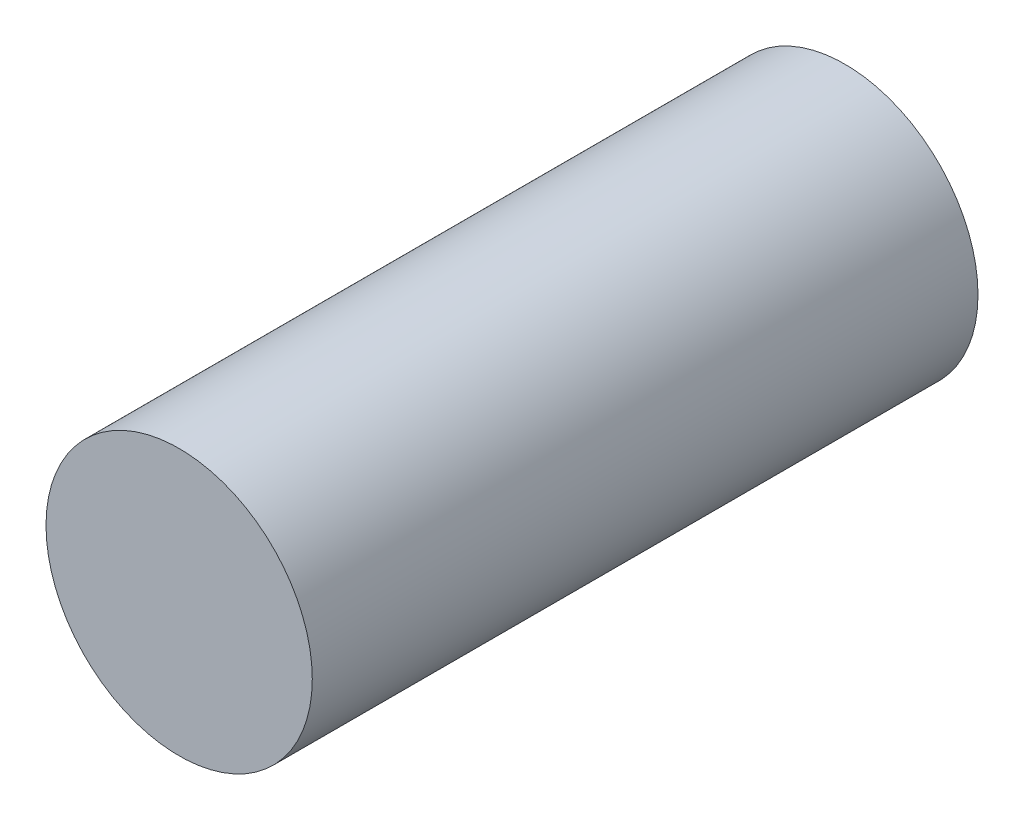
from build123d import *

# Parameters (mm, degrees)
SKETCH1_R           = 2
BOSS_EXTRUDE1_DEPTH = 10


with BuildPart() as part:
    # Sketch1 → Boss-Extrude1 (new body)
    with BuildSketch(Plane.XY):
        Circle(SKETCH1_R)
    extrude(amount=BOSS_EXTRUDE1_DEPTH)


solid = part.part
